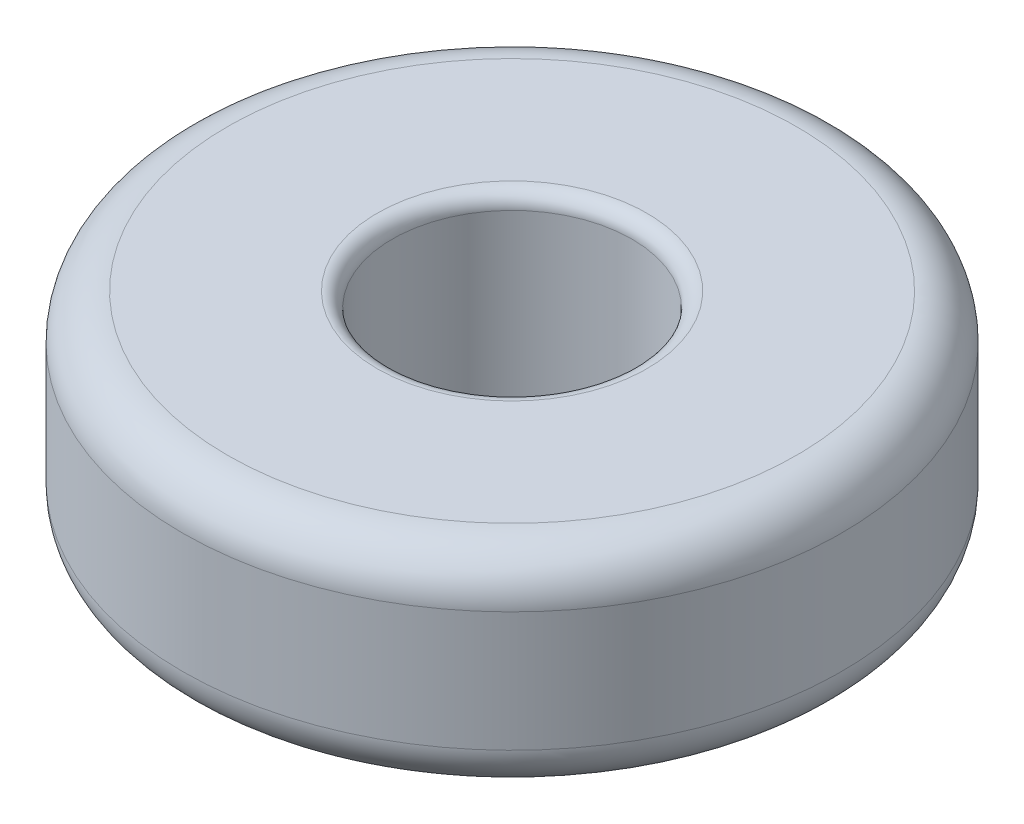
from build123d import *

# Parameters (mm, degrees)
SKETCH1_R           = 11
SKETCH1_R_2         = 4
BOSS_EXTRUDE1_DEPTH = 3.5
FILLET1_R           = 1.5
FILLET2_R           = 0.5


with BuildPart() as part:
    # Sketch1 → Boss-Extrude1 (new body, symmetric)
    with BuildSketch(Plane(origin=(0, 0, 0), x_dir=(1, 0, 0), z_dir=(0, 1, 0))):
        with Locations(Location((0, 0, 0), (0, 0, 270))):  # turned: the seam where the file's is
            Circle(SKETCH1_R)
        with Locations(Location((0, 0, 0), (0, 0, 270))):  # turned: the seam where the file's is
            Circle(SKETCH1_R_2, mode=Mode.SUBTRACT)
    extrude(amount=BOSS_EXTRUDE1_DEPTH, both=True)

    # Fillet1
    fillet1_edges = [part.edges().sort_by_distance(p)[0] for p in [
        (0, -3.5, -11),
        (0, 3.5, -11),
    ]]
    fillet(fillet1_edges, radius=FILLET1_R)

    # Fillet2
    fillet2_edges = [part.edges().sort_by_distance(p)[0] for p in [
        (0, -3.5, -4),
        (0, 3.5, -4),
    ]]
    fillet(fillet2_edges, radius=FILLET2_R)


solid = part.part
